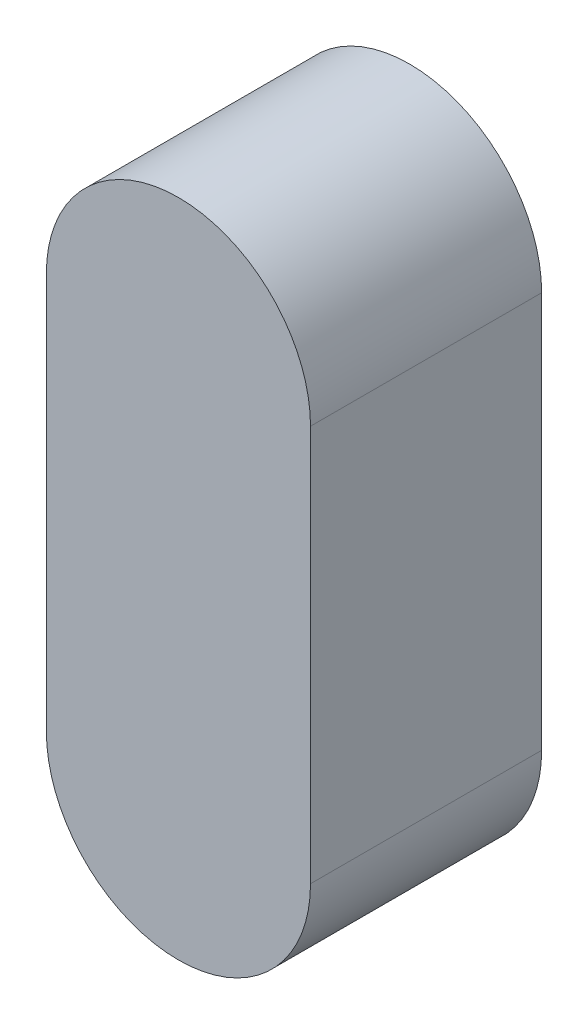
from build123d import *

# Parameters (mm, degrees)
P_IDAT_VYSUNUT_M1_DEPTH = 7


with BuildPart() as part:
    # Skica1 → Přidat vysunutím1 (new body)
    with BuildSketch(Plane.XY):
        with BuildLine():
            Line((-4, 0), (-4, 12))
            ThreePointArc((-4, 12), (0, 16), (4, 12))
            Line((4, 12), (4, 0))
            ThreePointArc((4, 0), (0, -4), (-4, 0))
        make_face()
    extrude(amount=P_IDAT_VYSUNUT_M1_DEPTH)


solid = part.part
